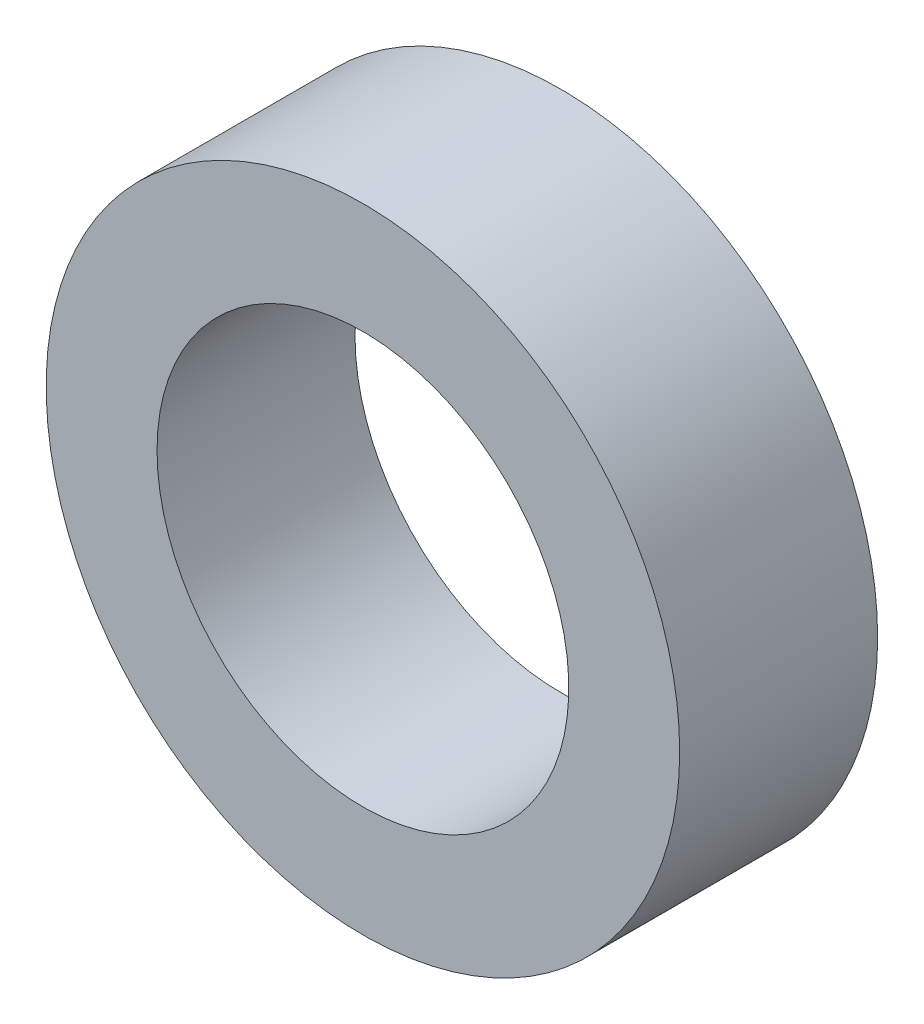
from build123d import *

# Parameters (mm, degrees)
SKETCH1_R          = 5.08
EXTRUDE1_DEPTH     = 3.175
SKETCH2_R          = 3.302
CUT_EXTRUDE1_DEPTH = 4.175


with BuildPart() as part:
    # Sketch1 → Extrude1 (new body)
    with BuildSketch(Plane.XY):
        Circle(SKETCH1_R)
    extrude(amount=EXTRUDE1_DEPTH)

    # Sketch2 → Cut-Extrude1 (cut, through all)
    with BuildSketch(Plane(origin=(0, 0, 0), x_dir=(-1, 0, 0), z_dir=(0, 0, -1))):
        Circle(SKETCH2_R)
    extrude(amount=-CUT_EXTRUDE1_DEPTH, mode=Mode.SUBTRACT)


solid = part.part
